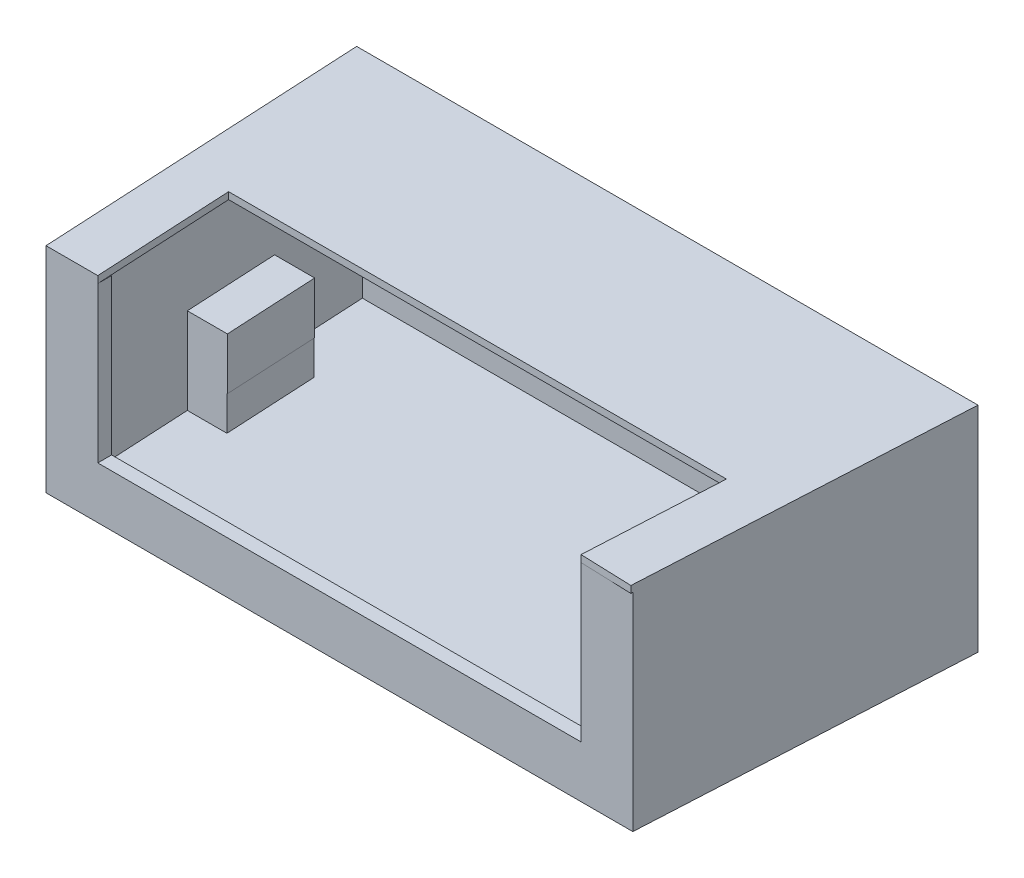
from build123d import *

# Parameters (mm, degrees)
EXTRUDE_1_DEPTH          = 600
CUT_EXTRUDE_1_DEPTH      = 300
CUT_EXTRUDE_2_DEPTH      = 310
CUT_EXTRUDE_2_DEPTH_BACK = 150
CUT_EXTRUDE_3_DEPTH      = 100
EXTRUDE_2_DEPTH          = 20


with BuildPart() as part:
    # Эскиз1 → Бобышка-Вытянуть1 (new body)
    with BuildSketch(Plane(origin=(0, 0, 0), x_dir=(1, 0, 0), z_dir=(0, 1, 0))):
        Polygon((-900, 950), (900, 950), (850, 0), (-850, 0), align=None)
    extrude(amount=EXTRUDE_1_DEPTH)

    # Эскиз3 → Вырез-Вытянуть1 (cut)
    with BuildSketch(Plane(origin=(0, 600, 0), x_dir=(1, 0, 0), z_dir=(0, 1, 0))):
        Polygon((-830.084404496, 896.603685423), (830.084404496, 896.603685423), (785, 40), (-785, 40), align=None)
    extrude(amount=-CUT_EXTRUDE_1_DEPTH, mode=Mode.SUBTRACT)

    # Эскиз4 → Вырез-Вытянуть2 (cut, two sides)
    with BuildSketch(Plane(origin=(0, 300, 0), x_dir=(1, 0, 0), z_dir=(0, 1, 0))) as cut_extrude_2_sk:
        Polygon((-830.084404496, 896.603685423), (830.084404496, 896.603685423), (815.955318169, 628.151045218), (709.135748769, 628.151045218), (695.096165279, 361.398958916), (801.91573468, 361.398958916), (785, 40), (700, 40), (700, 0), (-700, 0), (-700, 40), (-785, 40), (-801.91573468, 361.398958916), (-685.814283751, 361.398958916), (-699.85386724, 628.151045218), (-815.955318169, 628.151045218), align=None)
    extrude(amount=CUT_EXTRUDE_2_DEPTH, mode=Mode.SUBTRACT)
    extrude(cut_extrude_2_sk.sketch, amount=-CUT_EXTRUDE_2_DEPTH_BACK, mode=Mode.SUBTRACT)

    # Эскиз5 → Вырез-Вытянуть3 (cut)
    with BuildSketch(Plane(origin=(0, 150, 0), x_dir=(1, 0, 0), z_dir=(0, 1, 0))):
        Polygon((-830.084404496, 896.603685423), (-815.955318169, 628.151045218), (-701.325281658, 628.151045218), (-687.285698169, 361.398958916), (-801.91573468, 361.398958916), (-785, 40), (785, 40), (801.91573468, 361.398958916), (694.58093137, 361.398958916), (708.814837931, 628.151045218), (815.955318169, 628.151045218), (830.084404496, 896.603685423), align=None)
    extrude(amount=-CUT_EXTRUDE_3_DEPTH, mode=Mode.SUBTRACT)

    # Эскиз6 → Бобышка-Вытянуть2 (add)
    with BuildSketch(Plane(origin=(0, 600, 0), x_dir=(1, 0, 0), z_dir=(0, 1, 0))):
        Polygon((-900, 950), (-850, 0), (-700, 0), (-721.056000817, 400.064015528), (721.056000817, 400.064015528), (700, 0), (849.722904554, -5.264813473), (900, 950), align=None)
    extrude(amount=EXTRUDE_2_DEPTH)


solid = part.part
